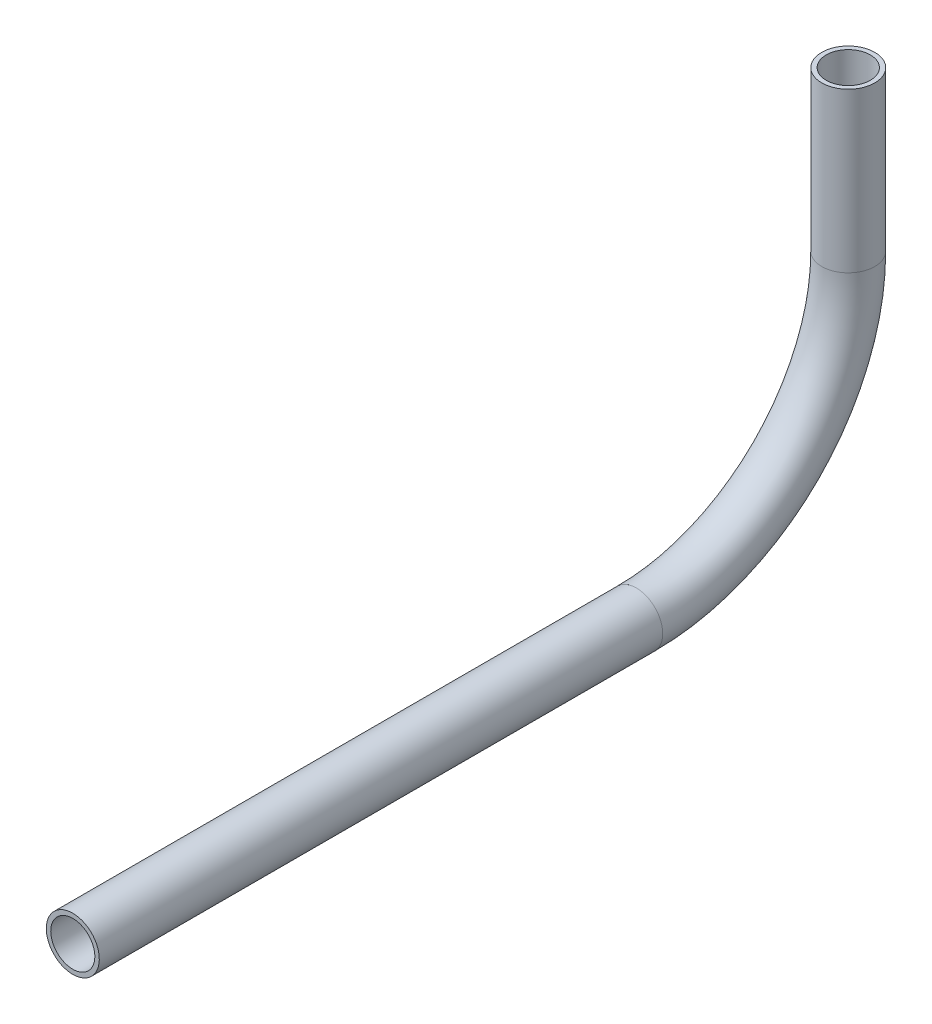
from build123d import *

# Parameters (mm, degrees)
SKETCH11_R                = 6.35
SKETCH11_R_2              = 5.2832
PIPE_0_5_SCH_40_1_DEPTH   = 134.99101558
SKETCH11_ON_SEGMENT_2_R   = 6.35
SKETCH11_ON_SEGMENT_2_R_2 = 5.2832
PIPE_0_5_SCH_40_1_2_ANGLE = 90
SKETCH11_ON_SEGMENT_3_R   = 6.35
SKETCH11_ON_SEGMENT_3_R_2 = 5.2832
PIPE_0_5_SCH_40_1_3_DEPTH = 38.1


with BuildPart() as part:
    # Sketch11 → Pipe 0.5 SCH 40(1) (new body)
    with BuildSketch(Plane(origin=(0, 670.165576631, 303.164595711), x_dir=(0, 1, 0), z_dir=(0, 0, -1))):
        Circle(SKETCH11_R)
        Circle(SKETCH11_R_2, mode=Mode.SUBTRACT)
    extrude(amount=PIPE_0_5_SCH_40_1_DEPTH)


with BuildPart() as body_2:
    # Sketch11 on segment 2 (carried to the start of arc 2) → Pipe 0.5 SCH 40_1 2 (revolve)
    with BuildSketch(Plane(origin=(0, 670.165576631, 168.173580131), x_dir=(0, 1, 0), z_dir=(0, 0, -1))):
        Circle(SKETCH11_ON_SEGMENT_2_R)
        Circle(SKETCH11_ON_SEGMENT_2_R_2, mode=Mode.SUBTRACT)
    revolve(axis=Axis((0, 720.965576631, 168.173580131), (1, 0, 0)), revolution_arc=PIPE_0_5_SCH_40_1_2_ANGLE)


with BuildPart() as body_3:
    # Sketch11 on segment 3 (carried to segment 3) → Pipe 0.5 SCH 40_1 3 (new body)
    with BuildSketch(Plane(origin=(0, 720.965576631, 117.373580131), x_dir=(0, 0, 1), z_dir=(0, 1, 0))):
        Circle(SKETCH11_ON_SEGMENT_3_R)
        Circle(SKETCH11_ON_SEGMENT_3_R_2, mode=Mode.SUBTRACT)
    extrude(amount=PIPE_0_5_SCH_40_1_3_DEPTH)


solid = Compound([part.part, body_2.part, body_3.part])
